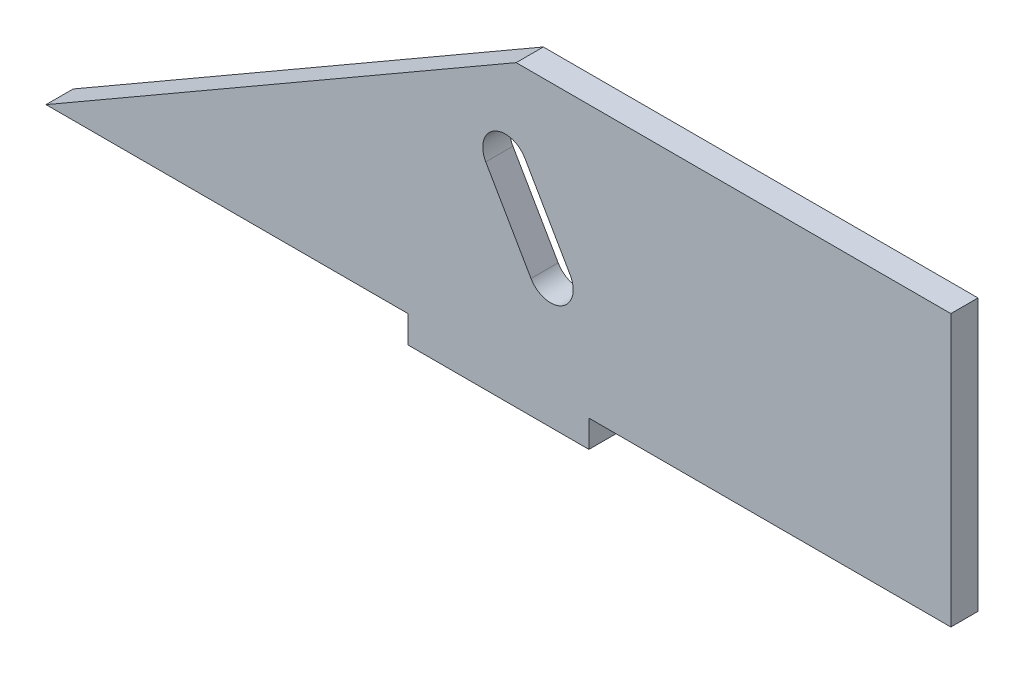
from build123d import *

# Parameters (mm, degrees)
BOSS_EXTRUDE1_DEPTH = 3
CUT_EXTRUDE1_DEPTH  = 4
CUT_EXTRUDE2_DEPTH  = 4


with BuildPart() as part:
    # Sketch1 → Boss-Extrude1 (new body)
    with BuildSketch(Plane.XY):
        Polygon((-10, -13), (-10, -16), (10, -16), (10, -13), (50, -13), (50, 17), (-50, 17), (-50, -13), align=None)
    extrude(amount=BOSS_EXTRUDE1_DEPTH)

    # Sketch2 → Cut-Extrude1 (cut)
    with BuildSketch(Plane.XY.offset(3)):
        Polygon((-50, -13), (1.961524227, 17), (-50, 17), align=None)
    extrude(amount=-CUT_EXTRUDE1_DEPTH, mode=Mode.SUBTRACT)

    # Sketch4 → Cut-Extrude2 (cut)
    with BuildSketch(Plane.XY.offset(3)):
        with BuildLine():
            Line((7.930435314, -0.338457268), (2.930435314, 8.32179677))
            ThreePointArc((2.930435314, 8.32179677), (-0.484628196, 9.236860279), (-1.399691705, 5.82179677))
            Line((-1.399691705, 5.82179677), (3.600308295, -2.838457268))
            ThreePointArc((3.600308295, -2.838457268), (7.015371804, -3.753520778), (7.930435314, -0.338457268))
        make_face()
    extrude(amount=-CUT_EXTRUDE2_DEPTH, mode=Mode.SUBTRACT)


solid = part.part
